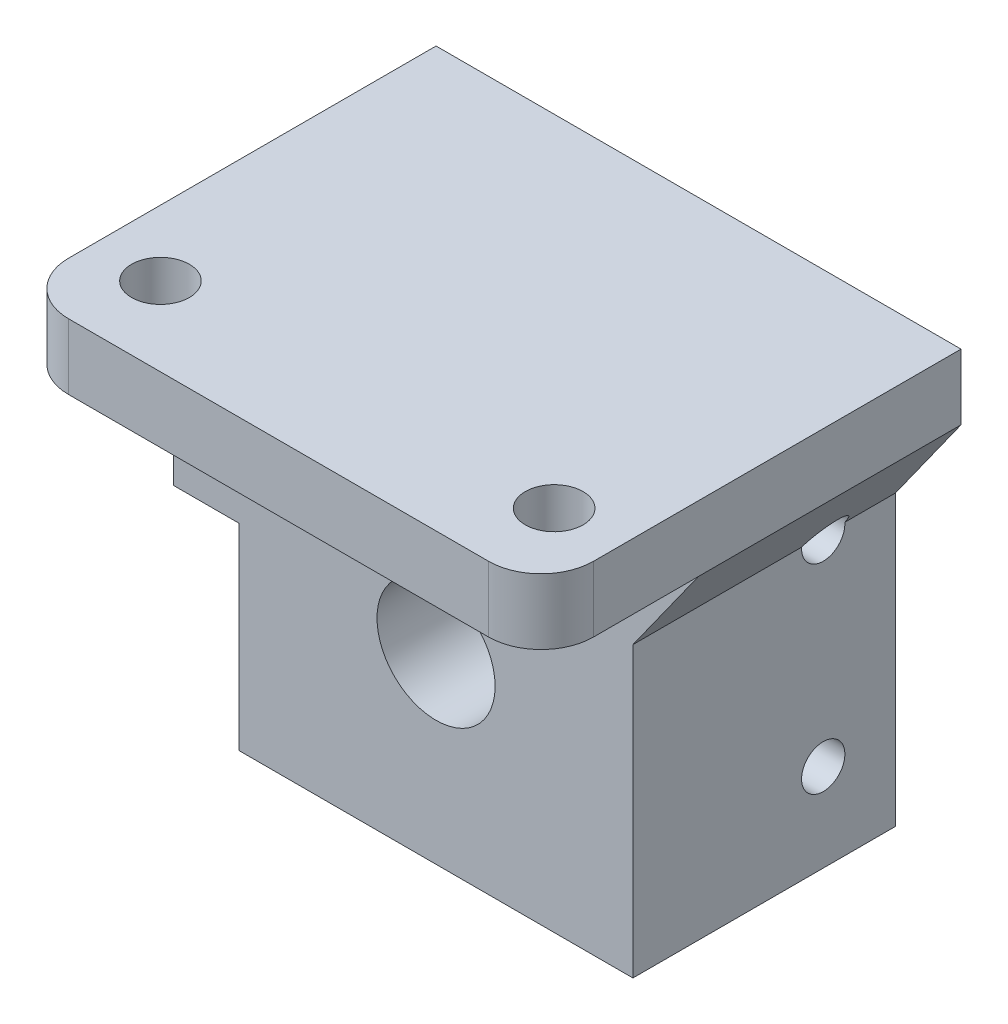
from build123d import *

# Parameters (mm, degrees)
ESQUISSE1_W                  = 40
ESQUISSE1_H                  = 34
BOSS_EXTRU_1_DEPTH           = 20
ESQUISSE2_W                  = 40
ESQUISSE2_H                  = 5
BOSS_EXTRU_3_DEPTH           = 20
ESQUISSE4_R                  = 4.5
ENL_V_MAT_EXTRU_1_DEPTH      = 21
ESQUISSE5_R                  = 8.1
ENL_V_MAT_EXTRU_2_DEPTH      = 12
ENL_V_MAT_EXTRU_3_DEPTH      = 21
ESQUISSE8_R                  = 2.2
ENL_V_MAT_EXTRU_5_DEPTH      = 6
ESQUISSE10_R                 = 4.5
BOSS_EXTRU_4_DEPTH           = 1
ESQUISSE11_W                 = 40
ESQUISSE11_H                 = 8
ENL_V_MAT_EXTRU_6_DEPTH      = 6
CONG_6_R                     = 4
ESQUISSE14_R                 = 1.65
ENL_V_MAT_EXTRU_7_DEPTH      = 6
ENL_V_MAT_EXTRU_7_DEPTH_BACK = 36


with BuildPart() as part:
    # Esquisse1 → Boss.-Extru.1 (new body)
    with BuildSketch(Plane.XY):
        Rectangle(ESQUISSE1_W, ESQUISSE1_H)
    extrude(amount=BOSS_EXTRU_1_DEPTH)

    # Esquisse2 → Boss.-Extru.3 (add)
    with BuildSketch(Plane.XY.offset(20)):
        with Locations((0, 14.5)):
            Rectangle(ESQUISSE2_W, ESQUISSE2_H)
    extrude(amount=BOSS_EXTRU_3_DEPTH)

    # Esquisse4 → Enlèv. mat.-Extru.1 (cut, through all)
    with BuildSketch(Plane.XY.offset(20)):
        with Locations((0, -3)):
            Circle(ESQUISSE4_R)
    extrude(amount=-ENL_V_MAT_EXTRU_1_DEPTH, mode=Mode.SUBTRACT)

    # Esquisse5 → Enlèv. mat.-Extru.2 (cut)
    with BuildSketch(Plane(origin=(0, 0, 0), x_dir=(-1, 0, 0), z_dir=(0, 0, -1))):
        with Locations((0, -3)):
            Circle(ESQUISSE5_R)
    extrude(amount=-ENL_V_MAT_EXTRU_2_DEPTH, mode=Mode.SUBTRACT)

    # Esquisse6 → Enlèv. mat.-Extru.3 (cut, through all)
    with BuildSketch(Plane.XY.offset(20)):
        Polygon((-20, -17), (-20, -2), (-15, -2), (-15, -7), (-15, -17), align=None)
        Polygon((20, 12), (15, 5), (15, -17), (20, -17), align=None)
    extrude(amount=-ENL_V_MAT_EXTRU_3_DEPTH, mode=Mode.SUBTRACT)

    # Esquisse8 → Enlèv. mat.-Extru.5 (cut, through all)
    with BuildSketch(Plane.XZ.offset(-12)):
        with Locations((-15, 26)):
            Circle(ESQUISSE8_R)
        with Locations((15, 26)):
            Circle(ESQUISSE8_R)
    extrude(amount=-ENL_V_MAT_EXTRU_5_DEPTH, mode=Mode.SUBTRACT)

    # Esquisse10 → Boss.-Extru.4 (add)
    with BuildSketch(Plane(origin=(0, 0, 12), x_dir=(-1, 0, 0), z_dir=(0, 0, -1))):
        with Locations((0, -3)):
            Circle(ESQUISSE10_R)
    extrude(amount=-BOSS_EXTRU_4_DEPTH)

    # Esquisse11 → Enlèv. mat.-Extru.6 (cut, through all)
    with BuildSketch(Plane.XZ.offset(-12)):
        with Locations((0, 36)):
            Rectangle(ESQUISSE11_W, ESQUISSE11_H)
    extrude(amount=-ENL_V_MAT_EXTRU_6_DEPTH, mode=Mode.SUBTRACT)

    # Congé6
    cong_6_edges = [part.edges().sort_by_distance(p)[0] for p in [
        (-20, 14.5, 32),
        (20, 14.5, 32),
    ]]
    fillet(cong_6_edges, radius=CONG_6_R)

    # Esquisse14 → Enlèv. mat.-Extru.7 (cut, two sides)
    with BuildSketch(Plane(origin=(15, 0, 0), x_dir=(0, 0, -1), z_dir=(1, 0, 0))) as enl_v_mat_extru_7_sk:
        with Locations((-5.5, -10.3)):
            Circle(ESQUISSE14_R)
        with Locations((-5.5, 4.9)):
            Circle(ESQUISSE14_R)
    extrude(amount=ENL_V_MAT_EXTRU_7_DEPTH, mode=Mode.SUBTRACT)
    extrude(enl_v_mat_extru_7_sk.sketch, amount=-ENL_V_MAT_EXTRU_7_DEPTH_BACK, mode=Mode.SUBTRACT)


solid = part.part
